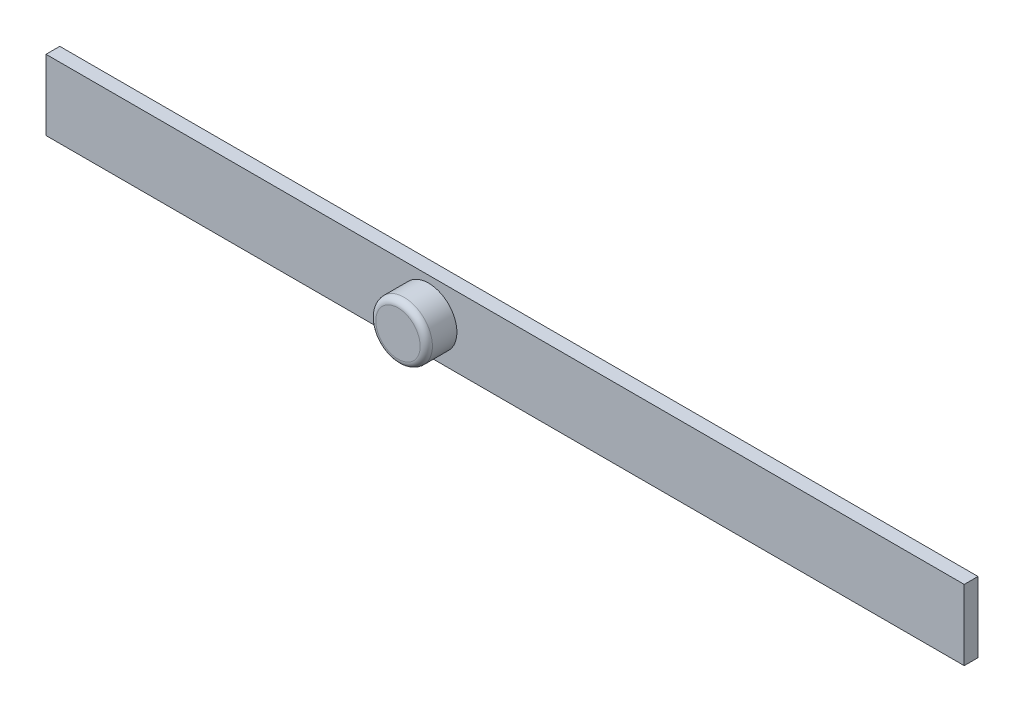
from build123d import *

# Parameters (mm, degrees)
SKICA1_W                = 60
SKICA1_H                = 4.6
P_IDAT_VYSUNUT_M1_DEPTH = 0.9
SKICA2_R                = 1.85
P_IDAT_VYSUNUT_M2_DEPTH = 2
ZAOBLIT1_R              = 0.4


with BuildPart() as part:
    # Skica1 → Přidat vysunutím1 (new body)
    with BuildSketch(Plane.XY):
        Rectangle(SKICA1_W, SKICA1_H)
    extrude(amount=P_IDAT_VYSUNUT_M1_DEPTH)

    # Skica2 → Přidat vysunutím2 (add)
    with BuildSketch(Plane.XY.offset(0.9)):
        with Locations((-5, 0)):
            Circle(SKICA2_R)
    extrude(amount=P_IDAT_VYSUNUT_M2_DEPTH)

    # Zaoblit1
    zaoblit1_edges = [part.edges().sort_by_distance(p)[0] for p in [
        (-6.85, 0, 2.9),
    ]]
    fillet(zaoblit1_edges, radius=ZAOBLIT1_R)


solid = part.part
